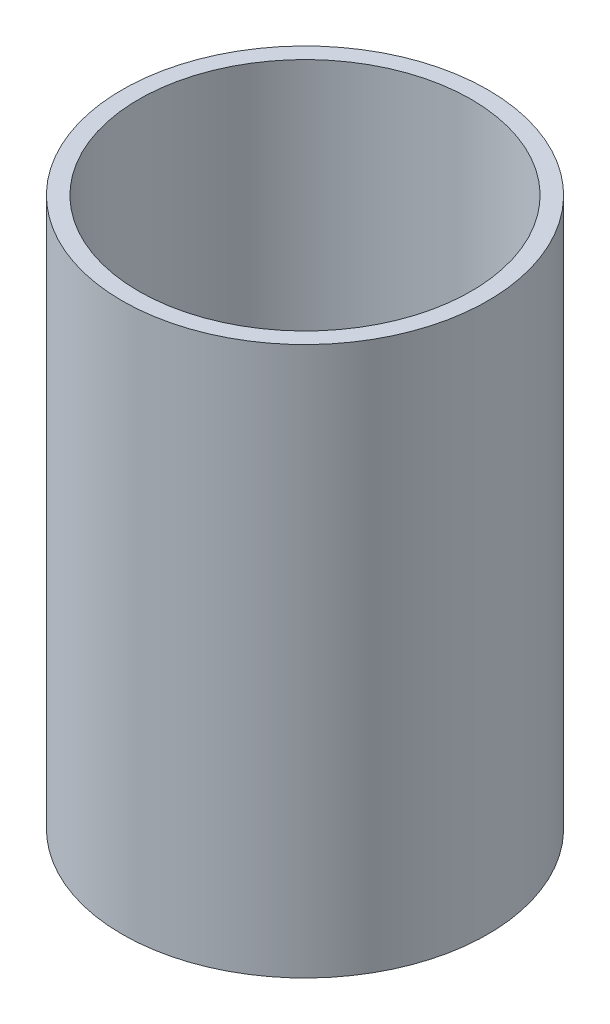
from build123d import *

# Parameters (mm, degrees)
SKETCH1_R           = 11
SKETCH1_R_2         = 10
BOSS_EXTRUDE1_DEPTH = 33


with BuildPart() as part:
    # Sketch1 → Boss-Extrude1 (new body)
    with BuildSketch(Plane(origin=(0, 0, 0), x_dir=(1, 0, 0), z_dir=(0, 1, 0))):
        Circle(SKETCH1_R)
        Circle(SKETCH1_R_2, mode=Mode.SUBTRACT)
    extrude(amount=BOSS_EXTRUDE1_DEPTH)


solid = part.part
